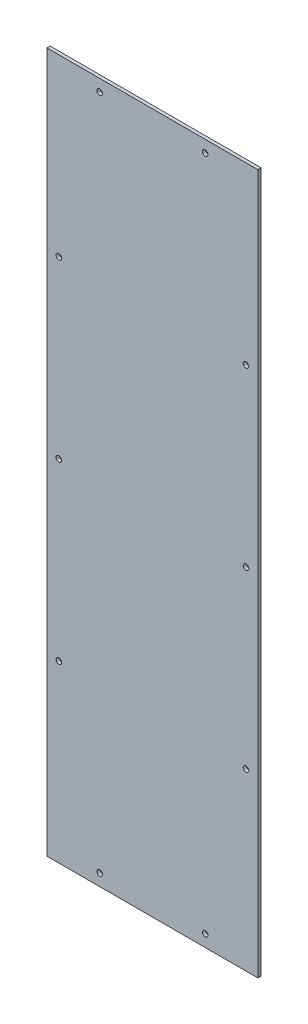
from build123d import *

# Parameters (mm, degrees)
SKETCH1_W           = 265.28
SKETCH1_H           = 880
BOSS_EXTRUDE1_DEPTH = 4
SKETCH2_R           = 3.5
CUT_EXTRUDE1_DEPTH  = 4


with BuildPart() as part:
    # Sketch1 → Boss-Extrude1 (new body)
    with BuildSketch(Plane.XY):
        with Locations((-258.91234657, 34.945848375)):
            Rectangle(SKETCH1_W, SKETCH1_H)
    extrude(amount=BOSS_EXTRUDE1_DEPTH)

    # Sketch2 → Cut-Extrude1 (cut)
    with BuildSketch(Plane.XY.offset(4)):
        with Locations((-325.23234657, 459.945848375)):
            Circle(SKETCH2_R)
        with Locations((-192.59234657, 459.945848375)):
            Circle(SKETCH2_R)
        with Locations((-325.23234657, -390.054151625)):
            Circle(SKETCH2_R)
        with Locations((-192.59234657, -390.054151625)):
            Circle(SKETCH2_R)
        with Locations((-376.55234657, 254.945848375)):
            Circle(SKETCH2_R)
        with Locations((-376.55234657, -185.054151625)):
            Circle(SKETCH2_R)
        with Locations((-141.27234657, -185.054151625)):
            Circle(SKETCH2_R)
        with Locations((-141.27234657, 254.945848375)):
            Circle(SKETCH2_R)
        with Locations((-376.55234657, 34.945848375)):
            Circle(SKETCH2_R)
        with Locations((-141.27234657, 34.945848375)):
            Circle(SKETCH2_R)
    extrude(amount=-CUT_EXTRUDE1_DEPTH, mode=Mode.SUBTRACT)


solid = part.part
